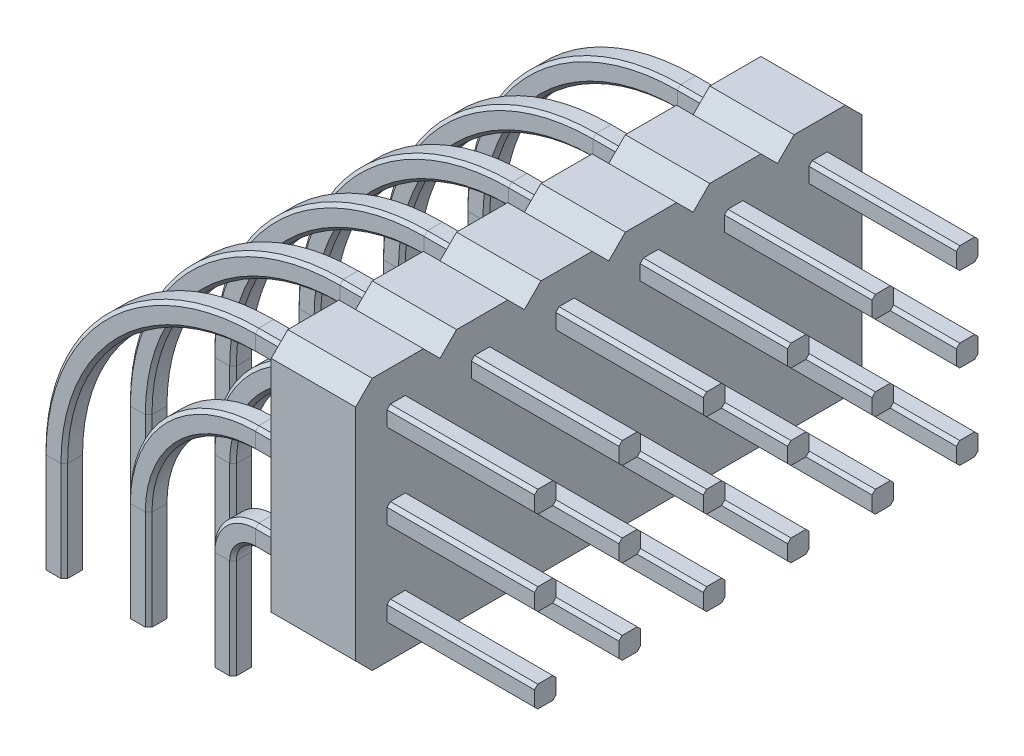
from build123d import *

# Parameters (mm, degrees)
BOSS_EXTRUDE1_DEPTH = 2.54
LPATTERN1_COUNT     = 6
LPATTERN1_PITCH     = 2.54


with BuildPart() as part:
    # Sweep1: sweep along a path in Sketch2
    with BuildLine(Plane.XY) as sweep1_path:
        Line((5.08, 0), (5.08, 3))
        ThreePointArc((5.08, 3), (5.372893219, 3.707106781), (6.08, 4))
        Line((6.08, 4), (14.48, 4))
    # Sketch1 → Sweep1 (sweep)
    with BuildSketch(Plane(origin=(0, 0, 0), x_dir=(1, 0, 0), z_dir=(0, 1, 0))):
        Polygon((0.225, 0.325), (0.325, 0.225), (0.325, -0.225), (0.225, -0.325), (-0.225, -0.325), (-0.325, -0.225), (-0.325, 0.225), (-0.225, 0.325), align=None)
        Polygon((2.215, 0.225), (2.215, -0.225), (2.315, -0.325), (2.765, -0.325), (2.865, -0.225), (2.865, 0.225), (2.765, 0.325), (2.315, 0.325), align=None)
        Polygon((4.755, 0.225), (4.755, -0.225), (4.855, -0.325), (5.305, -0.325), (5.405, -0.225), (5.405, 0.225), (5.305, 0.325), (4.855, 0.325), align=None)
    sweep(path=sweep1_path.line)

    # Sketch3 → Boss-Extrude1 (add)
    with BuildSketch(Plane(origin=(7.5, 0, 0), x_dir=(0, 0, -1), z_dir=(1, 0, 0))):
        Polygon((-0.77, 10.35), (0.77, 10.35), (1.27, 9.85), (1.27, 3.23), (0.77, 2.73), (-0.77, 2.73), (-1.27, 3.23), (-1.27, 9.85), align=None)
    extrude(amount=BOSS_EXTRUDE1_DEPTH)


with BuildPart() as lpattern1_1:
    # LPattern1: pattern copy
    add(part.part.moved(Location(Vector(0, 0, -1) * (1 * LPATTERN1_PITCH))))


with BuildPart() as lpattern1_2:
    # LPattern1: pattern copy
    add(part.part.moved(Location(Vector(0, 0, -1) * (2 * LPATTERN1_PITCH))))


with BuildPart() as lpattern1_3:
    # LPattern1: pattern copy
    add(part.part.moved(Location(Vector(0, 0, -1) * (3 * LPATTERN1_PITCH))))


with BuildPart() as lpattern1_4:
    # LPattern1: pattern copy
    add(part.part.moved(Location(Vector(0, 0, -1) * (4 * LPATTERN1_PITCH))))


with BuildPart() as lpattern1_5:
    # LPattern1: pattern copy
    add(part.part.moved(Location(Vector(0, 0, -1) * (5 * LPATTERN1_PITCH))))


with BuildPart() as part_1:
    add(part.part)

    # Combine1: union LPattern1_1, LPattern1_2, LPattern1_3, LPattern1_4, LPattern1_5
    add(lpattern1_1.part)
    add(lpattern1_2.part)
    add(lpattern1_3.part)
    add(lpattern1_4.part)
    add(lpattern1_5.part)


solid = part_1.part
